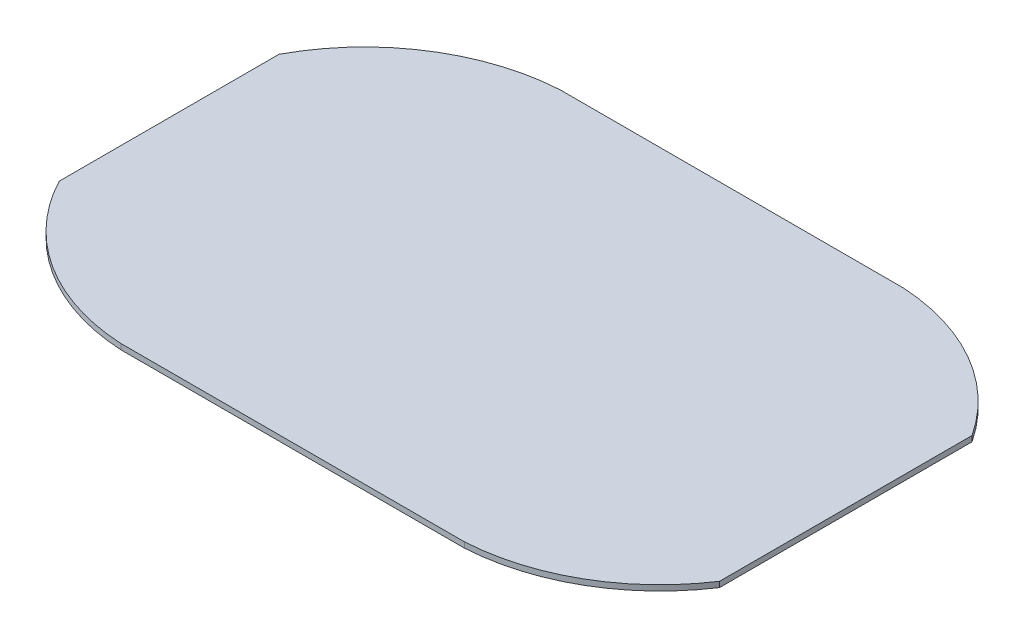
from build123d import *

# Parameters (mm, degrees)
SKETCH1_W           = 250
SKETCH1_H           = 160
BOSS_EXTRUDE1_DEPTH = 2
CUT_EXTRUDE2_DEPTH  = 50
SKETCH6_W           = 3.552127034
SKETCH6_H           = 144.927795072
CUT_EXTRUDE3_DEPTH  = 50


with BuildPart() as part:
    # Sketch1 → Boss-Extrude1 (new body)
    with BuildSketch(Plane(origin=(0, 0, 0), x_dir=(1, 0, 0), z_dir=(0, 1, 0))):
        Rectangle(SKETCH1_W, SKETCH1_H)
    extrude(amount=BOSS_EXTRUDE1_DEPTH)

    # Sketch5 → Cut-Extrude2 (cut)
    with BuildSketch(Plane(origin=(0, 2, 0), x_dir=(1, 0, 0), z_dir=(0, 1, 0))):
        with BuildLine():
            Line((-125, 40), (-125, 80))
            Line((-125, 80), (-62.5, 80))
            ThreePointArc((-62.5, 80), (-98.97872032, 68.169875501), (-125, 40))
        make_face()
        with BuildLine():
            Line((62.5, 80), (125, 80))
            Line((125, 80), (125, 40))
            ThreePointArc((125, 40), (98.978720329, 68.169875513), (62.5, 80))
        make_face()
        with BuildLine():
            Line((125, -40), (125, -80))
            Line((125, -80), (62.5, -80))
            ThreePointArc((62.5, -80), (98.978720329, -68.169875513), (125, -40))
        make_face()
        with BuildLine():
            Line((-62.5, -80), (-125, -80))
            Line((-125, -80), (-125, -40))
            ThreePointArc((-125, -40), (-99.075756291, -68.321494204), (-62.5, -80))
        make_face()
    extrude(amount=-CUT_EXTRUDE2_DEPTH, mode=Mode.SUBTRACT)

    # Sketch6 → Cut-Extrude3 (cut)
    with BuildSketch(Plane(origin=(0, 2, 0), x_dir=(1, 0, 0), z_dir=(0, 1, 0))):
        with Locations((123.223936483, 4.318146594)):
            Rectangle(SKETCH6_W, SKETCH6_H)
    extrude(amount=-CUT_EXTRUDE3_DEPTH, mode=Mode.SUBTRACT)


solid = part.part
